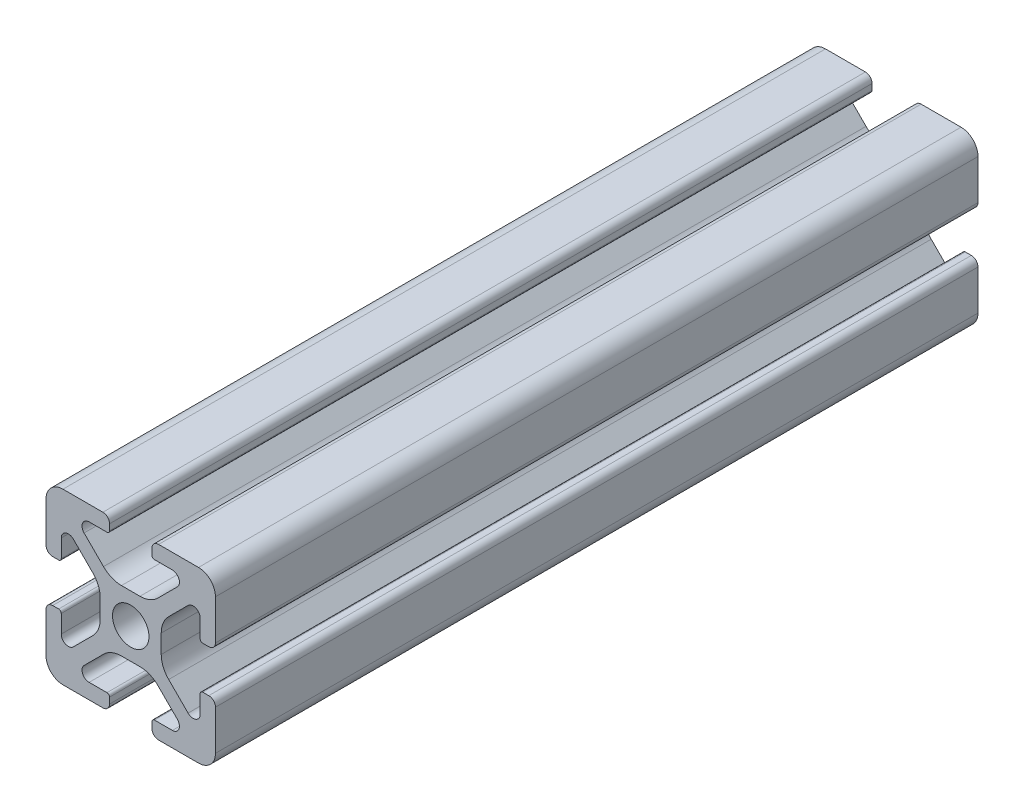
from build123d import *

# Parameters (mm, degrees)
SKETCH3_R                = 2.15
BOSS_EXTRUDE1_DEPTH      = 45
BOSS_EXTRUDE1_DEPTH_BACK = 45


with BuildPart() as part:
    # Sketch3 → Boss-Extrude1 (new body, two sides)
    with BuildSketch(Plane.XY) as boss_extrude1_sk:
        with BuildLine():
            Line((3.2874, 10), (8, 10))
            ThreePointArc((8, 10), (9.414213562, 9.414213562), (10, 8))
            Line((10, 8), (10, 3.2874))
            ThreePointArc((10, 3.2874), (9.76937588, 2.73062412), (9.2126, 2.5))
            Line((9.2126, 2.5), (8.5048, 2.5))
            ThreePointArc((8.5048, 2.5), (8.289273853, 2.589273853), (8.2, 2.8048))
            Line((8.2, 2.8048), (8.2, 4.9118))
            ThreePointArc((8.2, 4.9118), (7.682565253, 5.686195824), (6.769103096, 5.504496904))
            Line((6.769103096, 5.504496904), (4.478679656, 3.214073464))
            ThreePointArc((4.478679656, 3.214073464), (3.828361402, 2.240803418), (3.6, 1.092753121))
            Line((3.6, 1.092753121), (3.6, -1.092753121))
            ThreePointArc((3.6, -1.092753121), (3.828361402, -2.240803418), (4.478679656, -3.214073464))
            Line((4.478679656, -3.214073464), (6.769103096, -5.504496904))
            ThreePointArc((6.769103096, -5.504496904), (7.682565253, -5.686195824), (8.2, -4.9118))
            Line((8.2, -4.9118), (8.2, -2.8048))
            ThreePointArc((8.2, -2.8048), (8.289273853, -2.589273853), (8.5048, -2.5))
            Line((8.5048, -2.5), (9.2126, -2.5))
            ThreePointArc((9.2126, -2.5), (9.76937588, -2.73062412), (10, -3.2874))
            Line((10, -3.2874), (10, -8))
            ThreePointArc((10, -8), (9.414213562, -9.414213562), (8, -10))
            Line((8, -10), (3.2874, -10))
            ThreePointArc((3.2874, -10), (2.73062412, -9.76937588), (2.5, -9.2126))
            Line((2.5, -9.2126), (2.5, -8.5048))
            ThreePointArc((2.5, -8.5048), (2.589273853, -8.289273853), (2.8048, -8.2))
            Line((2.8048, -8.2), (4.9118, -8.2))
            ThreePointArc((4.9118, -8.2), (5.686195824, -7.682565253), (5.504496904, -6.769103096))
            Line((5.504496904, -6.769103096), (3.214073464, -4.478679656))
            ThreePointArc((3.214073464, -4.478679656), (2.240803418, -3.828361402), (1.092753121, -3.6))
            Line((1.092753121, -3.6), (-1.092753121, -3.6))
            ThreePointArc((-1.092753121, -3.6), (-2.240803418, -3.828361402), (-3.214073464, -4.478679656))
            Line((-3.214073464, -4.478679656), (-5.504496904, -6.769103096))
            ThreePointArc((-5.504496904, -6.769103096), (-5.686195824, -7.682565253), (-4.9118, -8.2))
            Line((-4.9118, -8.2), (-2.8048, -8.2))
            ThreePointArc((-2.8048, -8.2), (-2.589273853, -8.289273853), (-2.5, -8.5048))
            Line((-2.5, -8.5048), (-2.5, -9.2126))
            ThreePointArc((-2.5, -9.2126), (-2.73062412, -9.76937588), (-3.2874, -10))
            Line((-3.2874, -10), (-8, -10))
            ThreePointArc((-8, -10), (-9.414213562, -9.414213562), (-10, -8))
            Line((-10, -8), (-10, -3.2874))
            ThreePointArc((-10, -3.2874), (-9.76937588, -2.73062412), (-9.2126, -2.5))
            Line((-9.2126, -2.5), (-8.5048, -2.5))
            ThreePointArc((-8.5048, -2.5), (-8.289273853, -2.589273853), (-8.2, -2.8048))
            Line((-8.2, -2.8048), (-8.2, -4.9118))
            ThreePointArc((-8.2, -4.9118), (-7.682565253, -5.686195824), (-6.769103096, -5.504496904))
            Line((-6.769103096, -5.504496904), (-4.478679656, -3.214073464))
            ThreePointArc((-4.478679656, -3.214073464), (-3.828361402, -2.240803418), (-3.6, -1.092753121))
            Line((-3.6, -1.092753121), (-3.6, 1.092753121))
            ThreePointArc((-3.6, 1.092753121), (-3.828361402, 2.240803418), (-4.478679656, 3.214073464))
            Line((-4.478679656, 3.214073464), (-6.769103096, 5.504496904))
            ThreePointArc((-6.769103096, 5.504496904), (-7.682565253, 5.686195824), (-8.2, 4.9118))
            Line((-8.2, 4.9118), (-8.2, 2.8048))
            ThreePointArc((-8.2, 2.8048), (-8.289273853, 2.589273853), (-8.5048, 2.5))
            Line((-8.5048, 2.5), (-9.2126, 2.5))
            ThreePointArc((-9.2126, 2.5), (-9.76937588, 2.73062412), (-10, 3.2874))
            Line((-10, 3.2874), (-10, 8))
            ThreePointArc((-10, 8), (-9.414213562, 9.414213562), (-8, 10))
            Line((-8, 10), (-3.2874, 10))
            ThreePointArc((-3.2874, 10), (-2.73062412, 9.76937588), (-2.5, 9.2126))
            Line((-2.5, 9.2126), (-2.5, 8.5048))
            ThreePointArc((-2.5, 8.5048), (-2.589273853, 8.289273853), (-2.8048, 8.2))
            Line((-2.8048, 8.2), (-4.9118, 8.2))
            ThreePointArc((-4.9118, 8.2), (-5.686195824, 7.682565253), (-5.504496904, 6.769103096))
            Line((-5.504496904, 6.769103096), (-3.214073464, 4.478679656))
            ThreePointArc((-3.214073464, 4.478679656), (-2.240803418, 3.828361402), (-1.092753121, 3.6))
            Line((-1.092753121, 3.6), (1.092753121, 3.6))
            ThreePointArc((1.092753121, 3.6), (2.240803418, 3.828361402), (3.214073464, 4.478679656))
            Line((3.214073464, 4.478679656), (5.504496904, 6.769103096))
            ThreePointArc((5.504496904, 6.769103096), (5.686195824, 7.682565253), (4.9118, 8.2))
            Line((4.9118, 8.2), (2.8048, 8.2))
            ThreePointArc((2.8048, 8.2), (2.589273853, 8.289273853), (2.5, 8.5048))
            Line((2.5, 8.5048), (2.5, 9.2126))
            ThreePointArc((2.5, 9.2126), (2.73062412, 9.76937588), (3.2874, 10))
        make_face()
        Circle(SKETCH3_R, mode=Mode.SUBTRACT)
    extrude(amount=BOSS_EXTRUDE1_DEPTH)
    extrude(boss_extrude1_sk.sketch, amount=-BOSS_EXTRUDE1_DEPTH_BACK)


solid = part.part
